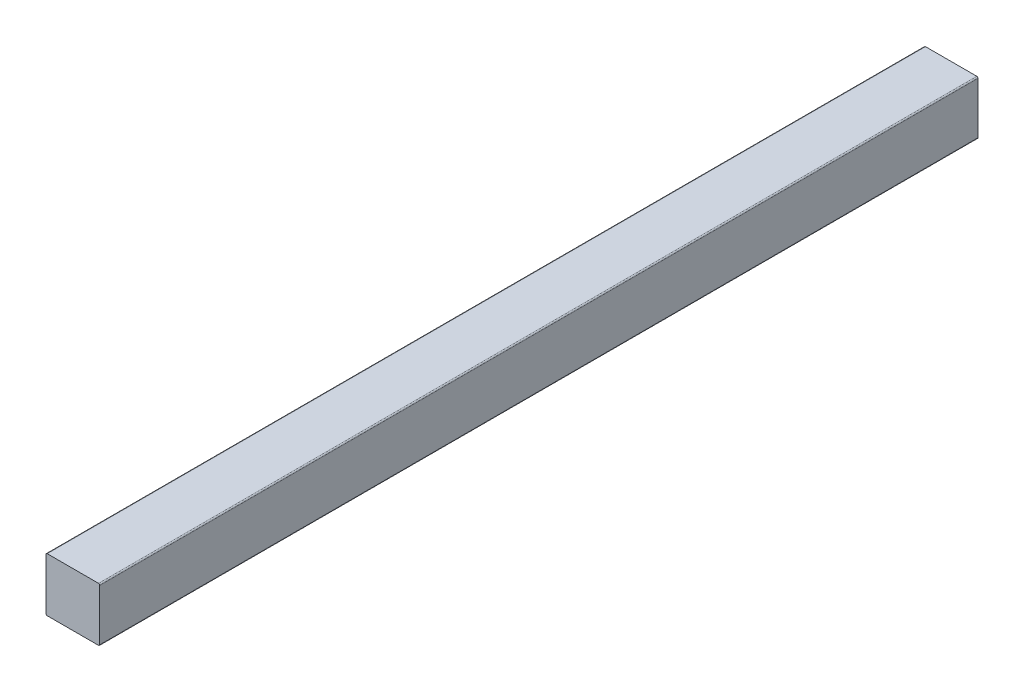
from build123d import *

# Parameters (mm, degrees)
SKETCH1_W           = 44
SKETCH1_H           = 44
BOSS_EXTRUDE1_DEPTH = 719
FILLET3_R           = 1


with BuildPart() as part:
    # Sketch1 → Boss-Extrude1 (new body)
    with BuildSketch(Plane.XY):
        with Locations((23, -12)):
            Rectangle(SKETCH1_W, SKETCH1_H)
    extrude(amount=BOSS_EXTRUDE1_DEPTH)

    # Fillet3
    fillet3_edges = [part.edges().sort_by_distance(p)[0] for p in [
        (1, 10, 359.5),
        (45, 10, 359.5),
        (45, -34, 359.5),
        (1, -34, 359.5),
    ]]
    fillet(fillet3_edges, radius=FILLET3_R)


solid = part.part
